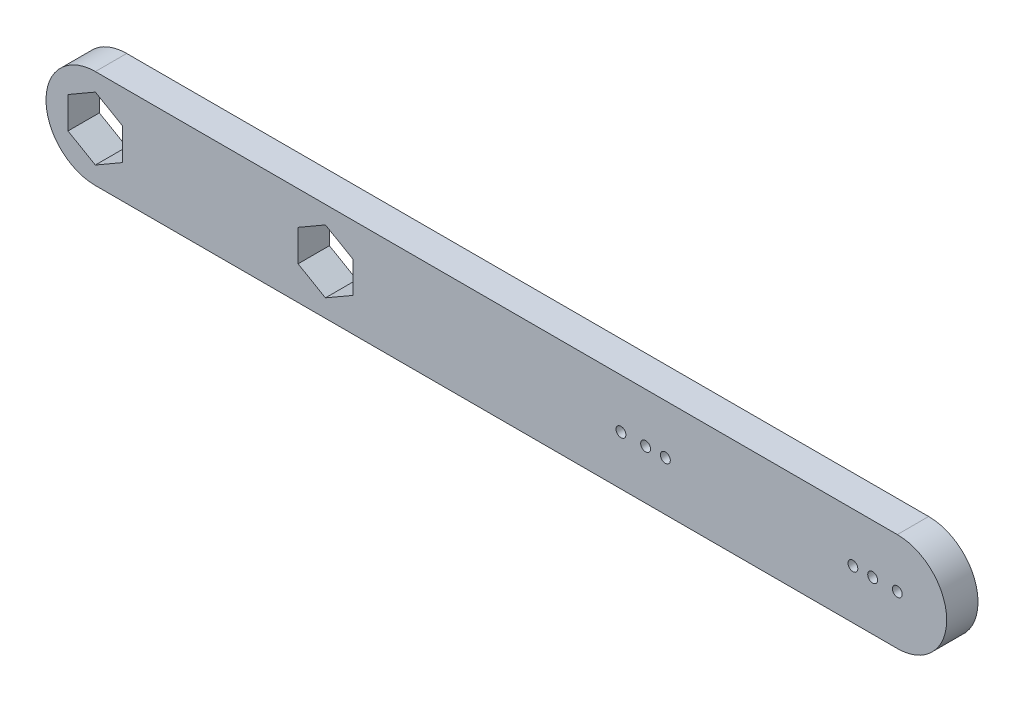
from build123d import *

# Parameters (mm, degrees)
SKETCH1_R           = 0.5
BOSS_EXTRUDE1_DEPTH = 3.175


with BuildPart() as part:
    # Sketch1 → Boss-Extrude1 (new body)
    with BuildSketch(Plane.XY):
        with BuildLine():
            Line((0, 5), (81.25, 5))
            ThreePointArc((81.25, 5), (86.25, 0), (81.25, -5))
            Line((81.25, -5), (0, -5))
            ThreePointArc((0, -5), (-5, 0), (0, 5))
        make_face()
        with Locations((81.25, 0)):
            Circle(SKETCH1_R, mode=Mode.SUBTRACT)
        with Locations((53.25, 0)):
            Circle(SKETCH1_R, mode=Mode.SUBTRACT)
        with Locations((55.75, 0)):
            Circle(SKETCH1_R, mode=Mode.SUBTRACT)
        with Locations((57.75, 0)):
            Circle(SKETCH1_R, mode=Mode.SUBTRACT)
        with Locations((78.75, 0)):
            Circle(SKETCH1_R, mode=Mode.SUBTRACT)
        with Locations((76.75, 0)):
            Circle(SKETCH1_R, mode=Mode.SUBTRACT)
        Polygon((0, 3.2), (-2.771281292, 1.6), (-2.771281292, -1.6), (0, -3.2), (2.771281292, -1.6), (2.771281292, 1.6), align=None, mode=Mode.SUBTRACT)
        Polygon((26.081281292, 1.6), (23.31, 3.2), (20.538718708, 1.6), (20.538718708, -1.6), (23.31, -3.2), (26.081281292, -1.6), align=None, mode=Mode.SUBTRACT)
    extrude(amount=BOSS_EXTRUDE1_DEPTH)


solid = part.part
